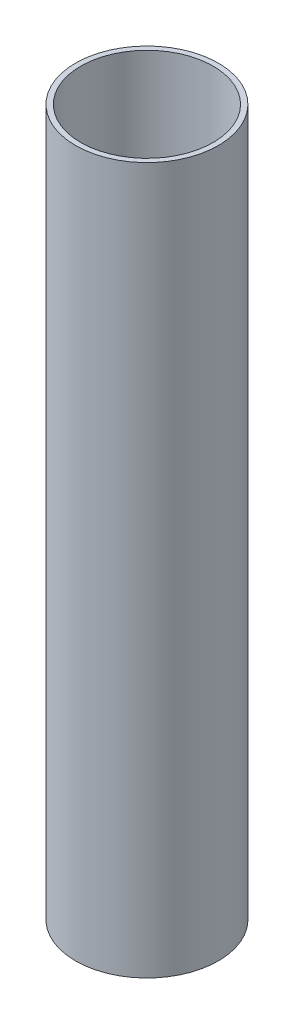
from build123d import *

# Parameters (mm, degrees)
SKETCH2_R           = 41.099994
SKETCH2_R_2         = 38.1
BOSS_EXTRUDE1_DEPTH = 406.4


with BuildPart() as part:
    # Sketch2 → Boss-Extrude1 (new body)
    with BuildSketch(Plane(origin=(0, 0, 0), x_dir=(1, 0, 0), z_dir=(0, 1, 0))):
        Circle(SKETCH2_R)
        Circle(SKETCH2_R_2, mode=Mode.SUBTRACT)
    extrude(amount=BOSS_EXTRUDE1_DEPTH)


solid = part.part
